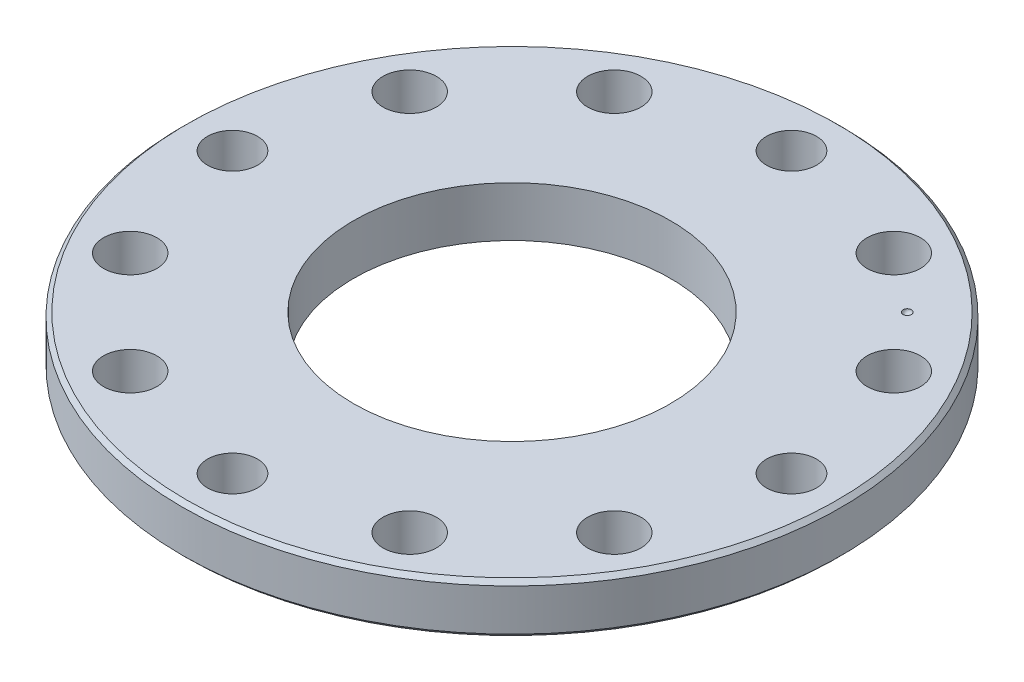
from build123d import *

# Parameters (mm, degrees)
SKETCH_1_R        = 39.5
SKETCH_1_R_2      = 19
SKETCH_1_R_3      = 3
EXTRUDE_1_DEPTH   = 6
HOLE_WIZARD_M61_D = 6.4
CHAMFER_1_SIZE    = 0.5


with BuildPart() as part:
    # Эскиз1 → Вытянуть1 (new body)
    with BuildSketch(Plane(origin=(0, 0, 0), x_dir=(1, 0, 0), z_dir=(0, 1, 0))):
        Circle(SKETCH_1_R)
        Circle(SKETCH_1_R_2, mode=Mode.SUBTRACT)
        with Locations((0, 33.5)):
            Circle(SKETCH_1_R_3, mode=Mode.SUBTRACT)
        with Locations((33.5, 0)):
            Circle(SKETCH_1_R_3, mode=Mode.SUBTRACT)
        with Locations((-33.5, 0)):
            Circle(SKETCH_1_R_3, mode=Mode.SUBTRACT)
        with Locations((0, -33.5)):
            Circle(SKETCH_1_R_3, mode=Mode.SUBTRACT)
    extrude(amount=-EXTRUDE_1_DEPTH)

    # Отверстие с зазором M61 (through all)
    with Locations(Plane(origin=(0, 0, 0), x_dir=(-1, 0, 0), z_dir=(0, 1, 0))):
        with Locations((16.75, 29.011851027), (29.011851027, -16.75), (-16.75, -29.011851027), (-29.011851027, 16.75), (16.75, -29.011851027), (-29.011851027, -16.75), (-16.75, 29.011851027), (29.011851027, 16.75)):
            Hole(HOLE_WIZARD_M61_D / 2)

    # Фаска1
    chamfer_1_edges = [part.edges().sort_by_distance(p)[0] for p in [
        (-39.5, 0, 0),
        (-39.5, -6, 0),
    ]]
    chamfer(chamfer_1_edges, length=CHAMFER_1_SIZE)

    # Эскиз5 → Вырез-Повернуть1 (revolve, cut)
    with BuildSketch(Plane(origin=(0, 0, 0), x_dir=(1, 0, 0), z_dir=(0, 1, 0))):
        with BuildLine():
            Line((24.04163056, 24.04163056), (23.334523779, 23.334523779))
            ThreePointArc((23.334523779, 23.334523779), (23.334523779, 24.04163056), (24.04163056, 24.04163056))
        make_face()
    revolve(axis=Axis((26.47587554, 0, -26.47587554), (-0.707106781, 0, 0.707106781)), mode=Mode.SUBTRACT)


solid = part.part
